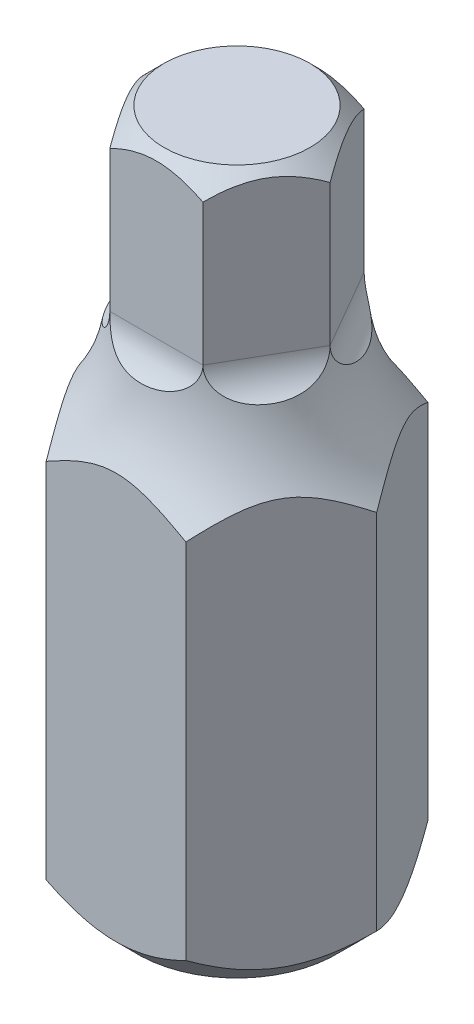
from build123d import *

# Parameters (mm, degrees)
BOSS_EXTRUDE1_DEPTH = 13
BOSS_EXTRUDE2_DEPTH = 4
SKETCH8_R           = 1
CUT_EXTRUDE1_DEPTH  = 4.464101715
CIRPATTERN1_COUNT   = 6


with BuildPart() as part:
    # Sketch2 → Boss-Extrude1 (new body)
    with BuildSketch(Plane(origin=(0, 0, 0), x_dir=(1, 0, 0), z_dir=(0, 1, 0))):
        Polygon((3.464101615, 0), (1.732050808, 3), (-1.732050808, 3), (-3.464101615, 0), (-1.732050808, -3), (1.732050808, -3), align=None)
    extrude(amount=BOSS_EXTRUDE1_DEPTH)

    # Sketch3 → Boss-Extrude2 (add)
    with BuildSketch(Plane(origin=(0, 13, 0), x_dir=(1, 0, 0), z_dir=(0, 1, 0))):
        Polygon((2.309401077, 0), (1.154700538, 2), (-1.154700538, 2), (-2.309401077, 0), (-1.154700538, -2), (1.154700538, -2), align=None)
    extrude(amount=BOSS_EXTRUDE2_DEPTH)

    # Sketch5 → Cut-Revolve2 (revolve, cut)
    with BuildSketch(Plane.XY):
        Polygon((3.464101615, 1), (2.464101615, 0), (3.464101615, 0), align=None)
        Polygon((1.809401077, 17), (2.309401077, 16.5), (2.309401077, 17), align=None)
        with BuildLine():
            Line((2.309401077, 13), (3.464101615, 13))
            Line((3.464101615, 13), (3.464101615, 9.990187462))
            ThreePointArc((3.464101615, 9.990187462), (2.607981818, 11.388145102), (2.309401077, 13))
        make_face()
    revolve(axis=Axis((0, 17, 0), (0, -1, 0)), mode=Mode.SUBTRACT)

    # Sketch8 → Cut-Extrude1 (cut, symmetric)
    with BuildSketch(Plane(origin=(0, 0, 0), x_dir=(0, 0, -1), z_dir=(1, 0, 0))):
        with Locations((3, 13)):
            Circle(SKETCH8_R)
    cut_extrude1 = extrude(amount=CUT_EXTRUDE1_DEPTH, both=True, mode=Mode.SUBTRACT)

    # CirPattern1: Cut-Extrude1 ×6 about axis
    cirpattern1_axis = Axis((0, 17, 0), (0, 1, 0))
    for i in range(1, CIRPATTERN1_COUNT):
        add(cut_extrude1.rotate(cirpattern1_axis, i * 360 / CIRPATTERN1_COUNT), mode=Mode.SUBTRACT)


solid = part.part
